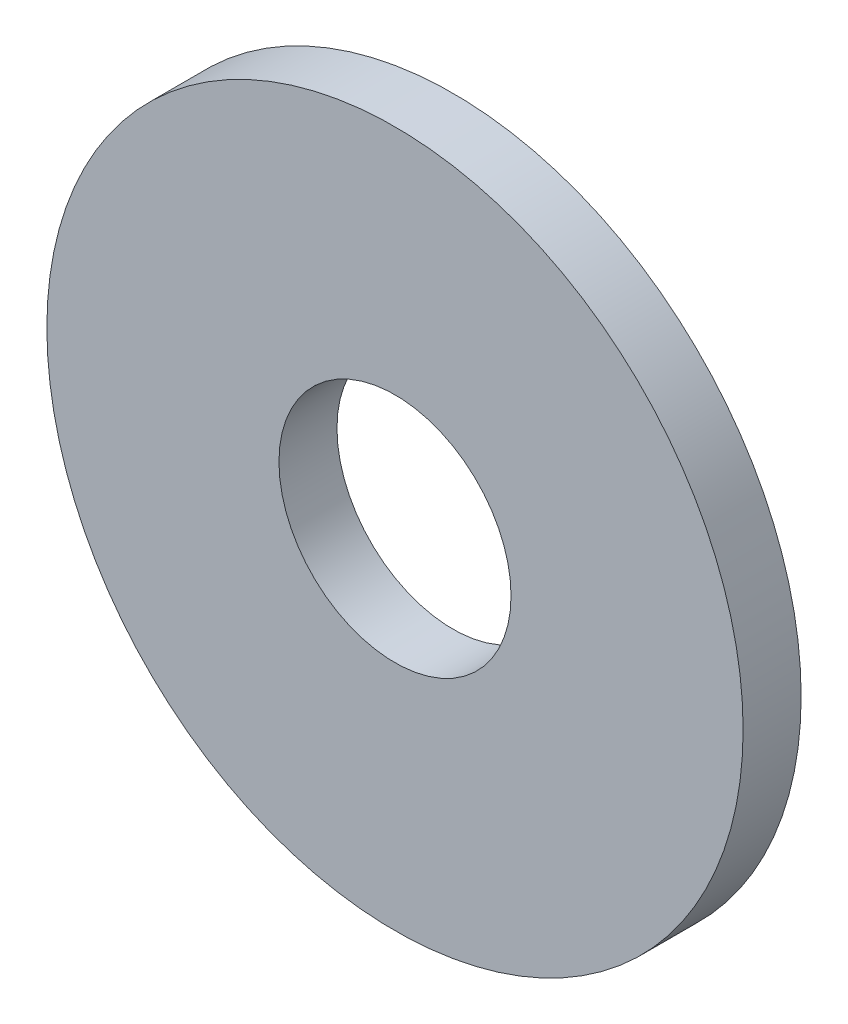
from build123d import *

# Parameters (mm, degrees)
SKETCH1_R           = 6
SKETCH1_R_2         = 2
BOSS_EXTRUDE2_DEPTH = 1


with BuildPart() as part:
    # Sketch1 → Boss-Extrude2 (new body)
    with BuildSketch(Plane.XY):
        Circle(SKETCH1_R)
        Circle(SKETCH1_R_2, mode=Mode.SUBTRACT)
    extrude(amount=BOSS_EXTRUDE2_DEPTH)


solid = part.part
